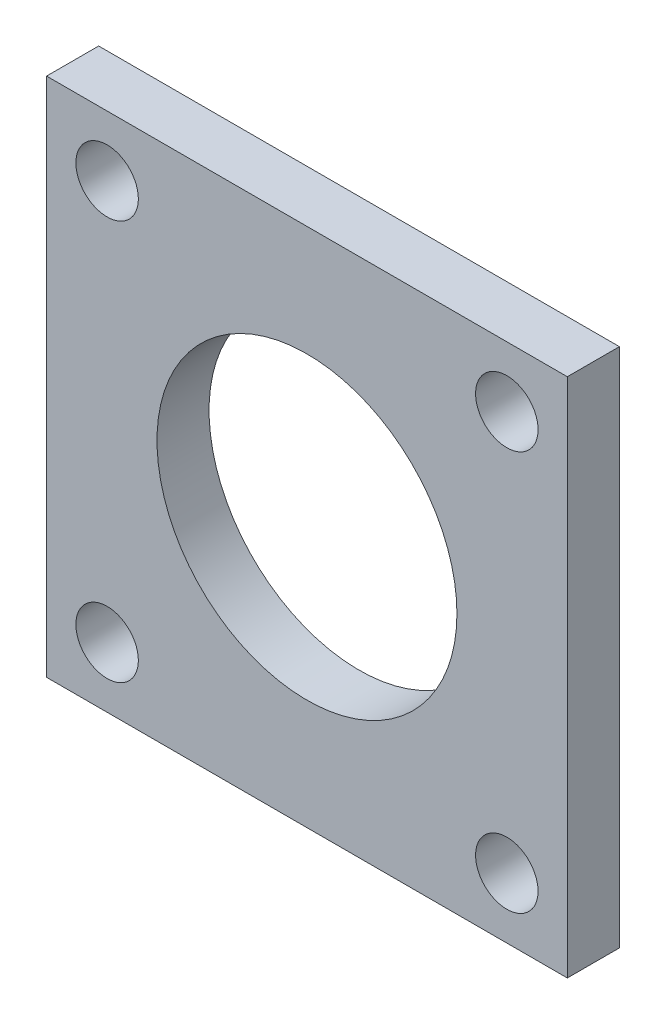
from build123d import *

# Parameters (mm, degrees)
SKETCH1_W           = 25.4
SKETCH1_H           = 25.4
SKETCH1_R           = 7.3152
SKETCH1_R_2         = 1.524
BOSS_EXTRUDE6_DEPTH = 2.54


with BuildPart() as part:
    # Sketch1 → Boss-Extrude6 (new body)
    with BuildSketch(Plane.XY):
        Rectangle(SKETCH1_W, SKETCH1_H)
        Circle(SKETCH1_R, mode=Mode.SUBTRACT)
        with Locations((9.748400853, 9.748400853)):
            Circle(SKETCH1_R_2, mode=Mode.SUBTRACT)
        with Locations((-9.748400853, -9.748400853)):
            Circle(SKETCH1_R_2, mode=Mode.SUBTRACT)
        with Locations((9.748400853, -9.748400853)):
            Circle(SKETCH1_R_2, mode=Mode.SUBTRACT)
        with Locations((-9.748400853, 9.748400853)):
            Circle(SKETCH1_R_2, mode=Mode.SUBTRACT)
    extrude(amount=BOSS_EXTRUDE6_DEPTH)


solid = part.part
